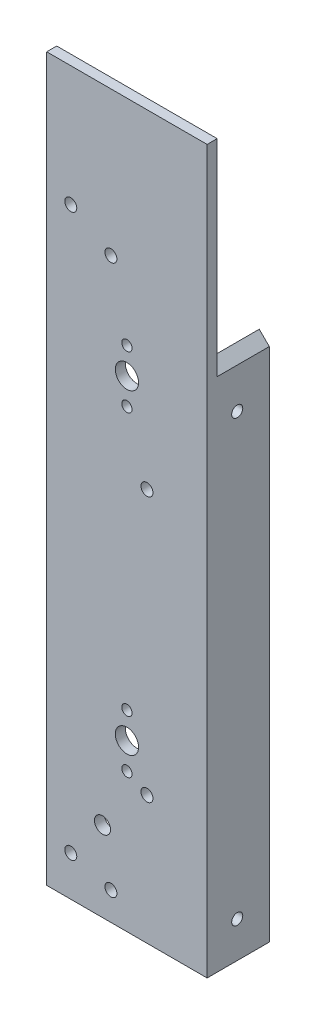
from build123d import *

# Parameters (mm, degrees)
BOSS_EXTRUDE1_DEPTH     = 203.2
CUT_EXTRUDE2_DEPTH      = 20.685
SKETCH5_R               = 3.683
SKETCH5_R_2             = 1.63195
CUT_EXTRUDE3_DEPTH      = 20.685
SKETCH6_R               = 1.7526
CUT_EXTRUDE4_DEPTH      = 51.8
SKETCH8_R               = 1.89865
CUT_EXTRUDE5_DEPTH      = 4.175
SKETCH9_R               = 1.89865
CUT_EXTRUDE6_DEPTH      = 4.175
BOSS_EXTRUDE2_DEPTH     = 3.175
SKETCH11_R              = 2.54
CUT_EXTRUDE7_DEPTH      = 20.685
SKETCH12_R              = 1.89865
CUT_EXTRUDE8_DEPTH      = 4.175
SKETCH13_R              = 3.683
SKETCH13_R_2            = 1.63195
CUT_EXTRUDE9_DEPTH      = 1
CUT_EXTRUDE9_DEPTH_BACK = 20.685


with BuildPart() as part:
    # Sketch1 → Boss-Extrude1 (new body)
    with BuildSketch(Plane(origin=(0, 0, 0), x_dir=(1, 0, 0), z_dir=(0, 1, 0))):
        Polygon((0, 0), (-50.8, 0), (-50.8, 3.175), (-3.175, 3.175), (-3.175, 19.685), (0, 19.685), align=None)
    extrude(amount=BOSS_EXTRUDE1_DEPTH)

    # Sketch4 → Cut-Extrude2 (cut, through all)
    with BuildSketch(Plane.XY):
        Polygon((-50.8, 214.122), (-57.250524058, 214.122), (-57.250524058, 247.071987418), (14.491605927, 247.071987418), (14.491605927, 163.322), (0, 163.322), align=None)
    extrude(amount=-CUT_EXTRUDE2_DEPTH, mode=Mode.SUBTRACT)

    # Sketch5 → Cut-Extrude3 (cut, through all)
    with BuildSketch(Plane.XY):
        with Locations((-25.4, 152.4)):
            Circle(SKETCH5_R)
        with Locations((-25.4, 160.782)):
            Circle(SKETCH5_R_2)
        with Locations((-25.4, 144.018)):
            Circle(SKETCH5_R_2)
    extrude(amount=-CUT_EXTRUDE3_DEPTH, mode=Mode.SUBTRACT)

    # Sketch6 → Cut-Extrude4 (cut, through all)
    with BuildSketch(Plane(origin=(0, 0, 0), x_dir=(0, 0, -1), z_dir=(1, 0, 0))):
        with Locations((9.530474513, 11.43)):
            Circle(SKETCH6_R)
        with Locations((9.530474513, 150.622)):
            Circle(SKETCH6_R)
    extrude(amount=-CUT_EXTRUDE4_DEPTH, mode=Mode.SUBTRACT)

    # Sketch8 → Cut-Extrude5 (cut, through all)
    with BuildSketch(Plane(origin=(0, 0, -3.175), x_dir=(-1, 0, 0), z_dir=(0, 0, -1))):
        with Locations((30.48, 8.89)):
            Circle(SKETCH8_R)
        with Locations((30.48, 182.88)):
            Circle(SKETCH8_R)
    extrude(amount=-CUT_EXTRUDE5_DEPTH, mode=Mode.SUBTRACT)

    # Sketch9 → Cut-Extrude6 (cut, through all)
    with BuildSketch(Plane(origin=(0, 0, -3.175), x_dir=(-1, 0, 0), z_dir=(0, 0, -1))):
        with Locations((19.05, 40.64)):
            Circle(SKETCH9_R)
        with Locations((19.05, 124.46)):
            Circle(SKETCH9_R)
    extrude(amount=-CUT_EXTRUDE6_DEPTH, mode=Mode.SUBTRACT)

    # Sketch10 → Boss-Extrude2 (add)
    with BuildSketch(Plane.XY):
        Polygon((0, 228.6), (0, 163.322), (-39.878, 203.2), (-50.8, 203.2), (-50.8, 228.6), align=None)
    extrude(amount=-BOSS_EXTRUDE2_DEPTH)

    # Sketch11 → Cut-Extrude7 (cut, through all)
    with BuildSketch(Plane.XY):
        with Locations((-33.136196499, 25.4)):
            Circle(SKETCH11_R)
    extrude(amount=-CUT_EXTRUDE7_DEPTH, mode=Mode.SUBTRACT)

    # Sketch12 → Cut-Extrude8 (cut, through all)
    with BuildSketch(Plane(origin=(0, 0, -3.175), x_dir=(-1, 0, 0), z_dir=(0, 0, -1))):
        with Locations((43.18, 12.7)):
            Circle(SKETCH12_R)
        with Locations((43.18, 190.498941664)):
            Circle(SKETCH12_R)
    extrude(amount=-CUT_EXTRUDE8_DEPTH, mode=Mode.SUBTRACT)

    # Sketch13 → Cut-Extrude9 (cut, two sides)
    with BuildSketch(Plane.XY) as cut_extrude9_sk:
        with Locations((-25.4, 52.4)):
            Circle(SKETCH13_R)
        with Locations((-25.4, 60.782)):
            Circle(SKETCH13_R_2)
        with Locations((-25.4, 44.018)):
            Circle(SKETCH13_R_2)
    extrude(amount=CUT_EXTRUDE9_DEPTH, mode=Mode.SUBTRACT)
    extrude(cut_extrude9_sk.sketch, amount=-CUT_EXTRUDE9_DEPTH_BACK, mode=Mode.SUBTRACT)


solid = part.part
